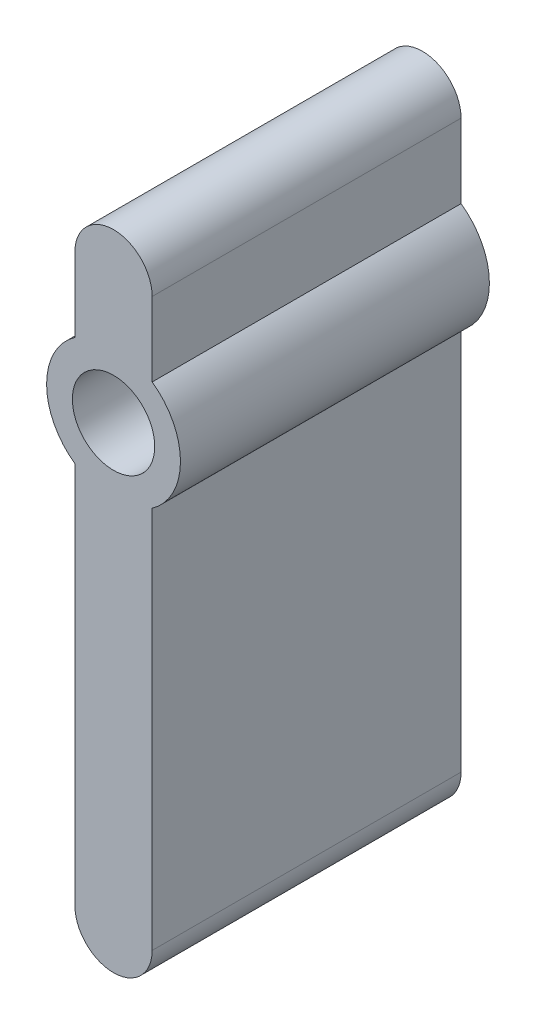
from build123d import *

# Parameters (mm, degrees)
SKETCH_1_R      = 1.6
EXTRUDE_1_DEPTH = 12


with BuildPart() as part:
    # 草图1 → 凸台-拉伸1 (new body)
    with BuildSketch(Plane.XY):
        with BuildLine():
            ThreePointArc((-1.5, 2.123676058), (-2.6, 0), (-1.5, -2.123676058))
            Line((-1.5, -2.123676058), (-1.5, -17))
            ThreePointArc((-1.5, -17), (0, -18.5), (1.5, -17))
            Line((1.5, -17), (1.5, -2.123676058))
            ThreePointArc((1.5, -2.123676058), (2.6, 0), (1.5, 2.123676058))
            Line((1.5, 2.123676058), (1.5, 5))
            ThreePointArc((1.5, 5), (0, 6.5), (-1.5, 5))
            Line((-1.5, 5), (-1.5, 2.123676058))
        make_face()
        Circle(SKETCH_1_R, mode=Mode.SUBTRACT)
    extrude(amount=EXTRUDE_1_DEPTH)


solid = part.part
